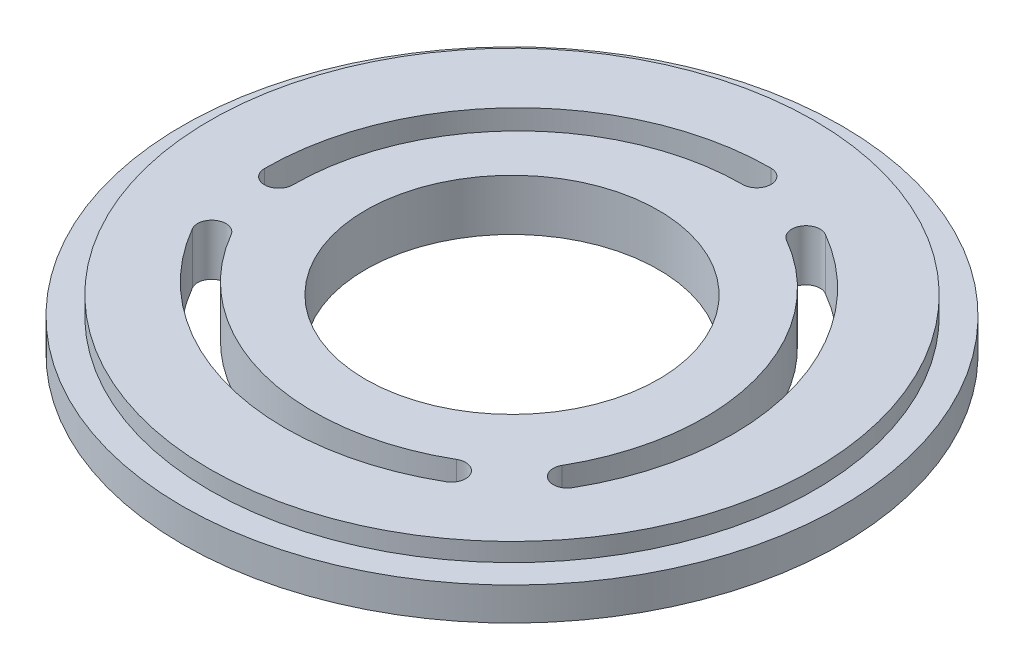
from build123d import *

# Parameters (mm, degrees)
SKETCH1_R           = 18
BOSS_EXTRUDE2_DEPTH = 1.8
SKETCH2_R           = 16.5
BOSS_EXTRUDE3_DEPTH = 1
SKETCH3_R           = 8
CUT_EXTRUDE1_DEPTH  = 5
CUT_EXTRUDE2_DEPTH  = 5


with BuildPart() as part:
    # Sketch1 → Boss-Extrude2 (new body)
    with BuildSketch(Plane(origin=(0, 0, 0), x_dir=(1, 0, 0), z_dir=(0, 1, 0))):
        Circle(SKETCH1_R)
    extrude(amount=-BOSS_EXTRUDE2_DEPTH)

    # Sketch2 → Boss-Extrude3 (add)
    with BuildSketch(Plane(origin=(0, 0, 0), x_dir=(1, 0, 0), z_dir=(0, 1, 0))):
        Circle(SKETCH2_R)
    extrude(amount=BOSS_EXTRUDE3_DEPTH)

    # Sketch3 → Cut-Extrude1 (cut)
    with BuildSketch(Plane(origin=(0, 1, 0), x_dir=(1, 0, 0), z_dir=(0, 1, 0))):
        Circle(SKETCH3_R)
    extrude(amount=-CUT_EXTRUDE1_DEPTH, mode=Mode.SUBTRACT)

    # Sketch5 → Cut-Extrude2 (cut)
    with BuildSketch(Plane(origin=(0, 1, 0), x_dir=(1, 0, 0), z_dir=(0, 1, 0))):
        with BuildLine():
            ThreePointArc((1.075948411, 13.068091917), (-8.698835605, 9.002564361), (-12.735889562, -0.784013805))
            ThreePointArc((-12.735889562, -0.784013805), (-11.960287094, -1.557361616), (-11.186939283, -0.781759147))
            ThreePointArc((-11.186939283, -0.781759147), (-7.601968074, 7.908885399), (1.078203069, 11.519141638))
            ThreePointArc((1.078203069, 11.519141638), (1.85155088, 12.294744107), (1.075948411, 13.068091917))
        make_face()
        with BuildLine():
            ThreePointArc((10.779325374, -7.465844616), (12.145867238, 3.032130437), (5.688968909, 11.421610803))
            ThreePointArc((5.688968909, 11.421610803), (4.631428825, 11.136593267), (4.916446361, 10.079053183))
            ThreePointArc((4.916446361, 10.079053183), (10.650279708, 2.629054772), (9.436767754, -6.693322067))
            ThreePointArc((9.436767754, -6.693322067), (9.72178529, -7.750862152), (10.779325374, -7.465844616))
        make_face()
        with BuildLine():
            ThreePointArc((-11.855273785, -5.602247302), (-3.447031633, -12.034694797), (7.046920653, -10.637596998))
            ThreePointArc((7.046920653, -10.637596998), (7.328858269, -9.579231652), (6.270492922, -9.297294036))
            ThreePointArc((6.270492922, -9.297294036), (-3.048311634, -10.537940171), (-10.514970823, -4.825819571))
            ThreePointArc((-10.514970823, -4.825819571), (-11.573336169, -4.543881955), (-11.855273785, -5.602247302))
        make_face()
    extrude(amount=-CUT_EXTRUDE2_DEPTH, mode=Mode.SUBTRACT)


solid = part.part
